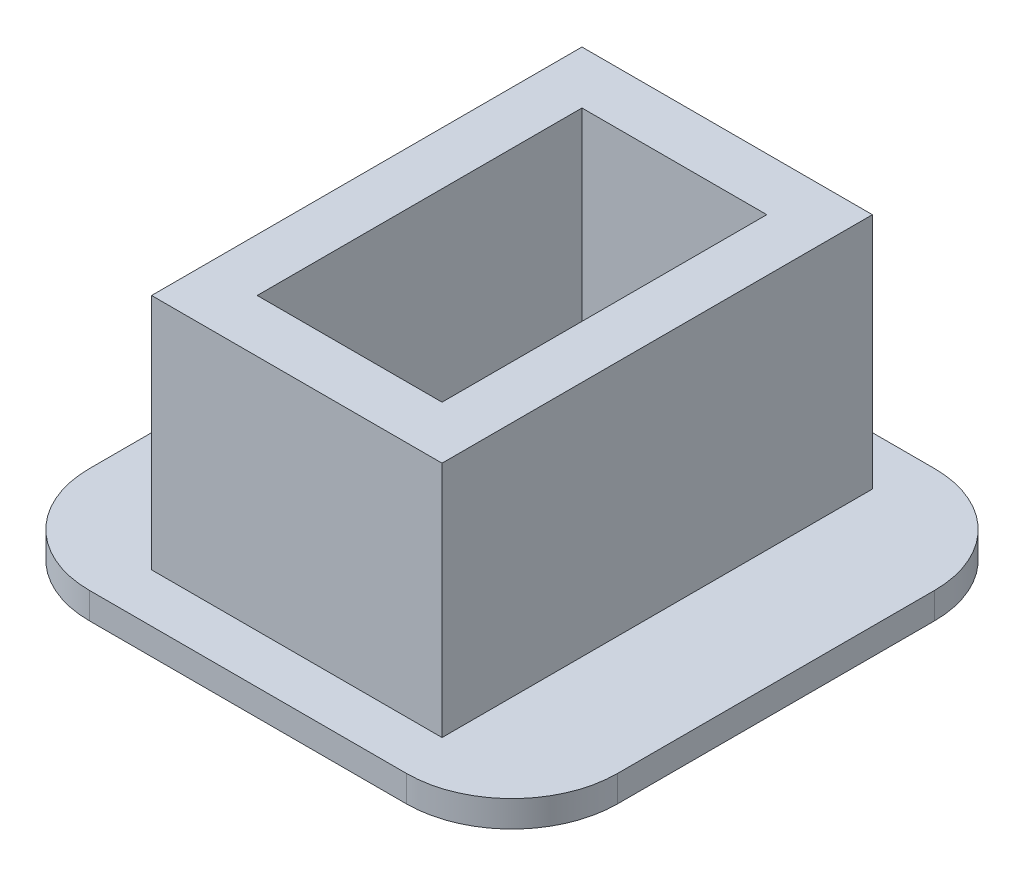
from build123d import *

# Parameters (mm, degrees)
SKETCH1_W           = 22
SKETCH1_H           = 32.6
SKETCH1_W_2         = 14
SKETCH1_H_2         = 24.6
BOSS_EXTRUDE1_DEPTH = 18
SKETCH3_W           = 40
SKETCH3_H           = 40
BOSS_EXTRUDE2_DEPTH = 2
FILLET1_R           = 8


with BuildPart() as part:
    # Sketch1 → Boss-Extrude1 (new body)
    with BuildSketch(Plane(origin=(0, 0, 0), x_dir=(1, 0, 0), z_dir=(0, 1, 0))):
        Rectangle(SKETCH1_W, SKETCH1_H)
        Rectangle(SKETCH1_W_2, SKETCH1_H_2, mode=Mode.SUBTRACT)
    extrude(amount=BOSS_EXTRUDE1_DEPTH)

    # Sketch3 → Boss-Extrude2 (add)
    with BuildSketch(Plane.XZ):
        Rectangle(SKETCH3_W, SKETCH3_H)
    extrude(amount=BOSS_EXTRUDE2_DEPTH)

    # Fillet1
    fillet1_edges = [part.edges().sort_by_distance(p)[0] for p in [
        (20, -1, -20),
        (20, -1, 20),
        (-20, -1, 20),
        (-20, -1, -20),
    ]]
    fillet(fillet1_edges, radius=FILLET1_R)


solid = part.part
